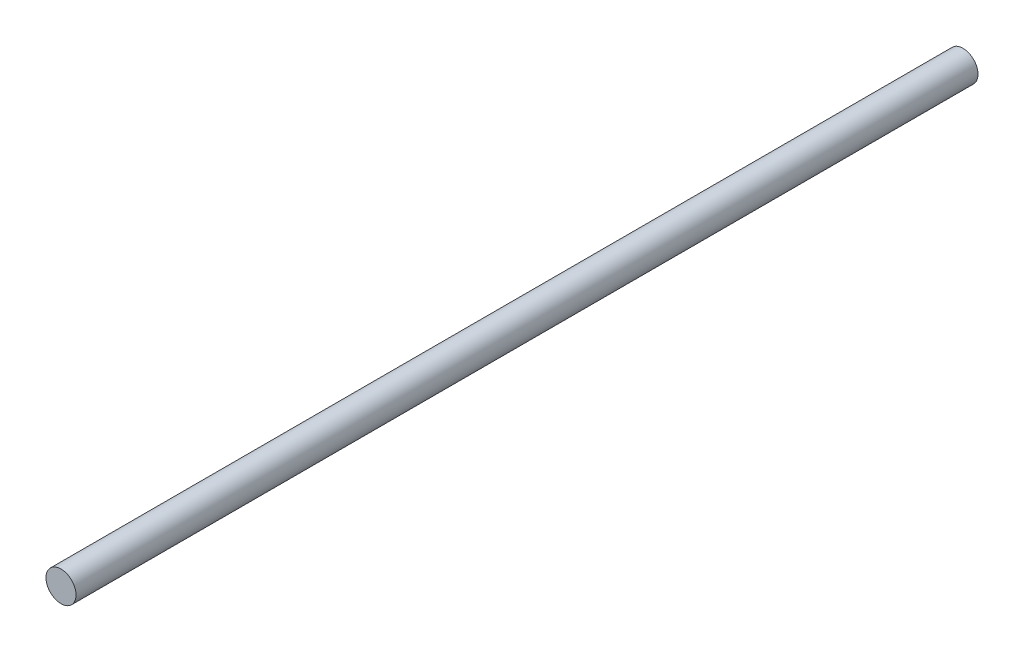
from build123d import *

# Parameters (mm, degrees)
SKETCH1_R           = 0.635
BOSS_EXTRUDE1_DEPTH = 38.1


with BuildPart() as part:
    # Sketch1 → Boss-Extrude1 (new body)
    with BuildSketch(Plane.XY):
        Circle(SKETCH1_R)
    extrude(amount=BOSS_EXTRUDE1_DEPTH)


solid = part.part
